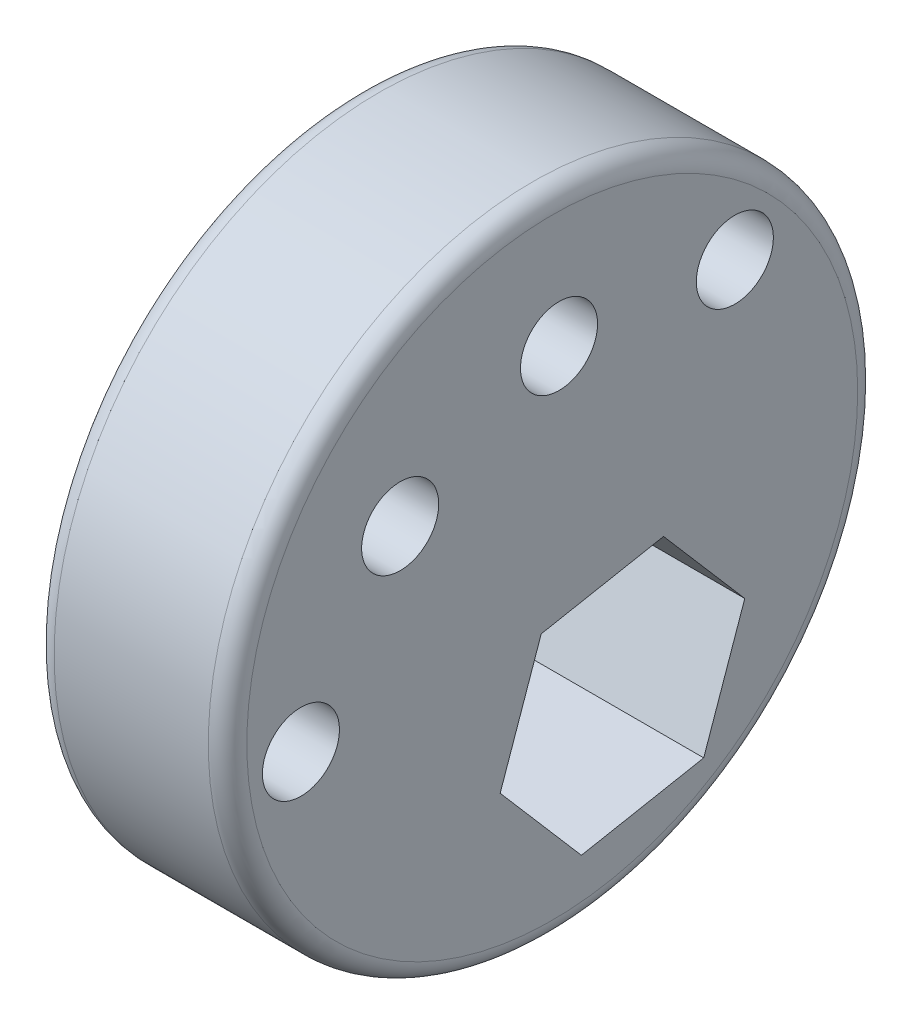
from build123d import *

# Parameters (mm, degrees)
SKIZZE1_R                       = 8.425
AUFSATZ_LINEAR_AUSTRAGEN1_DEPTH = 5
SKIZZE2_R                       = 1
SCHNITT_LINEAR_AUSTRAGEN1_DEPTH = 5
VERRUNDUNG5_R                   = 0.5
VERRUNDUNG6_R                   = 0.5


with BuildPart() as part:
    # Skizze1 → Aufsatz-Linear austragen1 (new body)
    with BuildSketch(Plane(origin=(0, 0, 0), x_dir=(0, 0, -1), z_dir=(1, 0, 0))):
        Circle(SKIZZE1_R)
    extrude(amount=AUFSATZ_LINEAR_AUSTRAGEN1_DEPTH)

    # Skizze2 → Schnitt-Linear austragen1 (cut)
    with BuildSketch(Plane(origin=(0, 0, 0), x_dir=(0, 0, -1), z_dir=(1, 0, 0))):
        with Locations((4.737160117, 4.550403752)):
            Circle(SKIZZE2_R)
        with Locations((0.175068654, 4.890321488)):
            Circle(SKIZZE2_R)
        with Locations((-3.945777315, 2.90365315)):
            Circle(SKIZZE2_R)
        with Locations((-6.521200441, -0.877275083)):
            Circle(SKIZZE2_R)
        Polygon((-0.286116888, -1.345269379), (2.887315481, -0.743416411), (4.995251626, -3.190762977), (3.929755401, -6.23996251), (0.756323031, -6.841815478), (-1.351613114, -4.394468913), align=None)
    extrude(amount=SCHNITT_LINEAR_AUSTRAGEN1_DEPTH, mode=Mode.SUBTRACT)

    # Verrundung5
    verrundung5_edges = [part.edges().sort_by_distance(p)[0] for p in [
        (5, 0, 8.425),
    ]]
    fillet(verrundung5_edges, radius=VERRUNDUNG5_R)

    # Verrundung6
    verrundung6_edges = [part.edges().sort_by_distance(p)[0] for p in [
        (0, 0, 8.425),
    ]]
    fillet(verrundung6_edges, radius=VERRUNDUNG6_R)


solid = part.part
